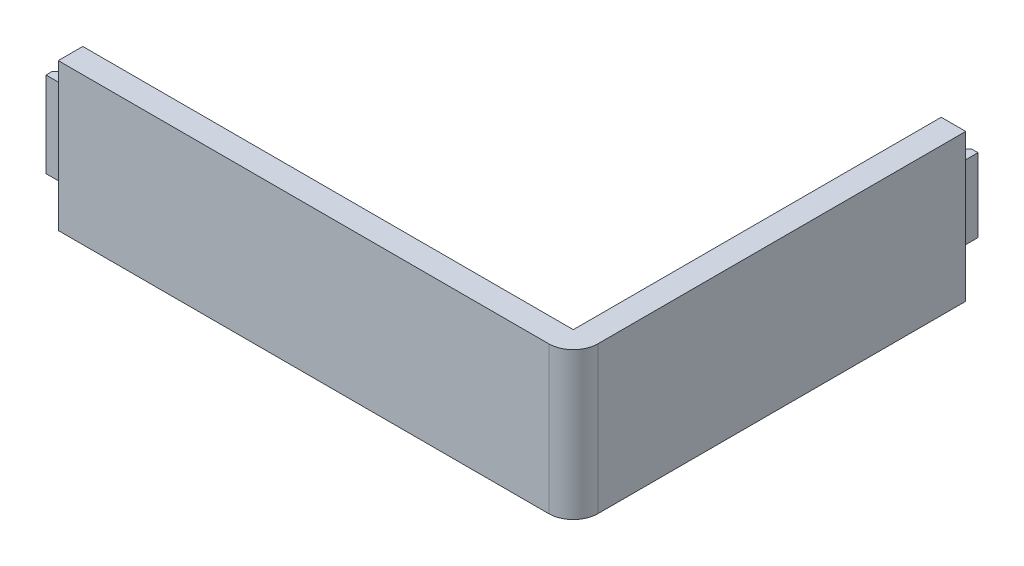
from build123d import *

# Parameters (mm, degrees)
BOSS_EXTRUDE1_DEPTH = 30
SKETCH2_W           = 2.5
SKETCH2_H           = 17.424704808
BOSS_EXTRUDE2_DEPTH = 5
CHAMFER1_SIZE       = 1.25
SKETCH3_W           = 2.5
SKETCH3_H           = 15
BOSS_EXTRUDE3_DEPTH = 5
CHAMFER2_SIZE       = 1.25
FILLET1_R           = 5


with BuildPart() as part:
    # Sketch1 → Boss-Extrude1 (new body)
    with BuildSketch(Plane(origin=(0, 0, 0), x_dir=(1, 0, 0), z_dir=(0, 1, 0))):
        Polygon((0, 0), (105, 0), (105, 80), (100, 80), (100, 5), (0, 5), align=None)
    extrude(amount=BOSS_EXTRUDE1_DEPTH)

    # Sketch2 → Boss-Extrude2 (add)
    with BuildSketch(Plane.ZY):
        with Locations((-3.75, 15)):
            Rectangle(SKETCH2_W, SKETCH2_H)
    extrude(amount=BOSS_EXTRUDE2_DEPTH)

    # Chamfer1
    chamfer1_edges = [part.edges().sort_by_distance(p)[0] for p in [
        (-5, 15, -5),
    ]]
    chamfer(chamfer1_edges, length=CHAMFER1_SIZE)

    # Sketch3 → Boss-Extrude3 (add)
    with BuildSketch(Plane(origin=(0, 0, -80), x_dir=(-1, 0, 0), z_dir=(0, 0, -1))):
        with Locations((-101.25, 15)):
            Rectangle(SKETCH3_W, SKETCH3_H)
    extrude(amount=BOSS_EXTRUDE3_DEPTH)

    # Chamfer2
    chamfer2_edges = [part.edges().sort_by_distance(p)[0] for p in [
        (100, 15, -85),
    ]]
    chamfer(chamfer2_edges, length=CHAMFER2_SIZE)

    # Fillet1
    fillet1_edges = [part.edges().sort_by_distance(p)[0] for p in [
        (105, 15, 0),
    ]]
    fillet(fillet1_edges, radius=FILLET1_R)


solid = part.part
